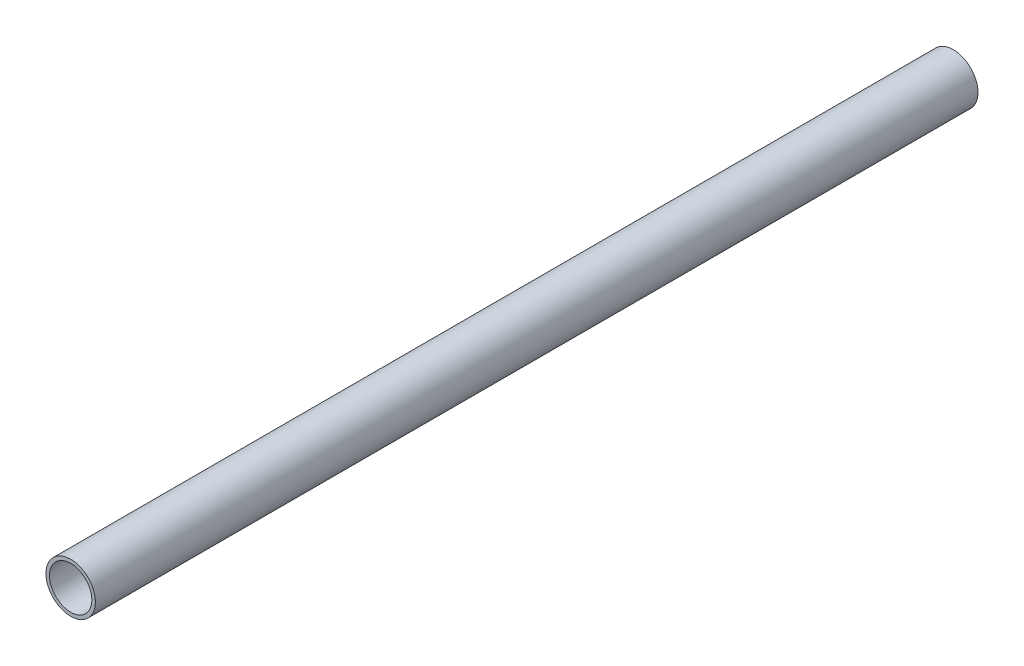
from build123d import *

# Parameters (mm, degrees)
SKETCH_1_R          = 14
EXTRUDE_1_DEPTH     = 500
SKETCH_2_R          = 12
CUT_EXTRUDE_1_DEPTH = 501


with BuildPart() as part:
    # Эскиз1 → Бобышка-Вытянуть1 (new body)
    with BuildSketch(Plane.XY):
        Circle(SKETCH_1_R)
    extrude(amount=EXTRUDE_1_DEPTH)

    # Эскиз2 → Вырез-Вытянуть1 (cut, through all)
    with BuildSketch(Plane(origin=(0, 0, 0), x_dir=(-1, 0, 0), z_dir=(0, 0, -1))):
        Circle(SKETCH_2_R)
    extrude(amount=-CUT_EXTRUDE_1_DEPTH, mode=Mode.SUBTRACT)


solid = part.part
